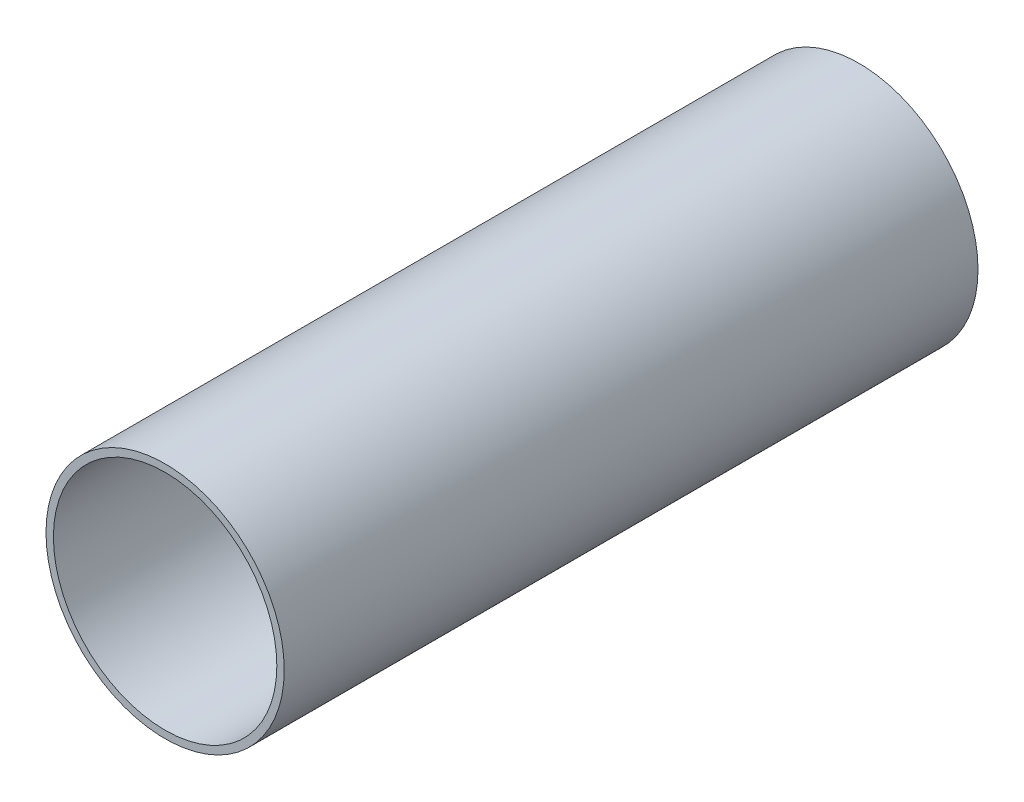
from build123d import *

# Parameters (mm, degrees)
SKETCH1_R           = 101.3
SKETCH1_R_2         = 95
BOSS_EXTRUDE1_DEPTH = 590


with BuildPart() as part:
    # Sketch1 → Boss-Extrude1 (new body)
    with BuildSketch(Plane.XY):
        Circle(SKETCH1_R)
        Circle(SKETCH1_R_2, mode=Mode.SUBTRACT)
    extrude(amount=BOSS_EXTRUDE1_DEPTH)


solid = part.part
